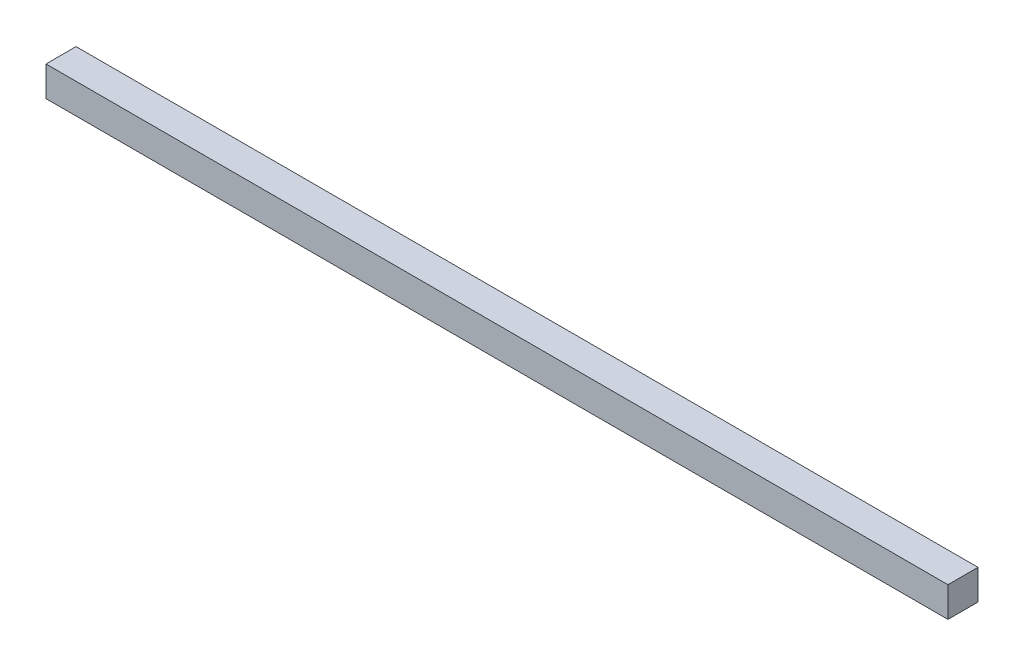
from build123d import *

# Parameters (mm, degrees)
SKETCH1_W           = 300
SKETCH1_H           = 10
BOSS_EXTRUDE1_DEPTH = 10


with BuildPart() as part:
    # Sketch1 → Boss-Extrude1 (new body)
    with BuildSketch(Plane(origin=(0, 0, 0), x_dir=(1, 0, 0), z_dir=(0, 1, 0))):
        with Locations((150, 5)):
            Rectangle(SKETCH1_W, SKETCH1_H)
    extrude(amount=BOSS_EXTRUDE1_DEPTH)


solid = part.part
